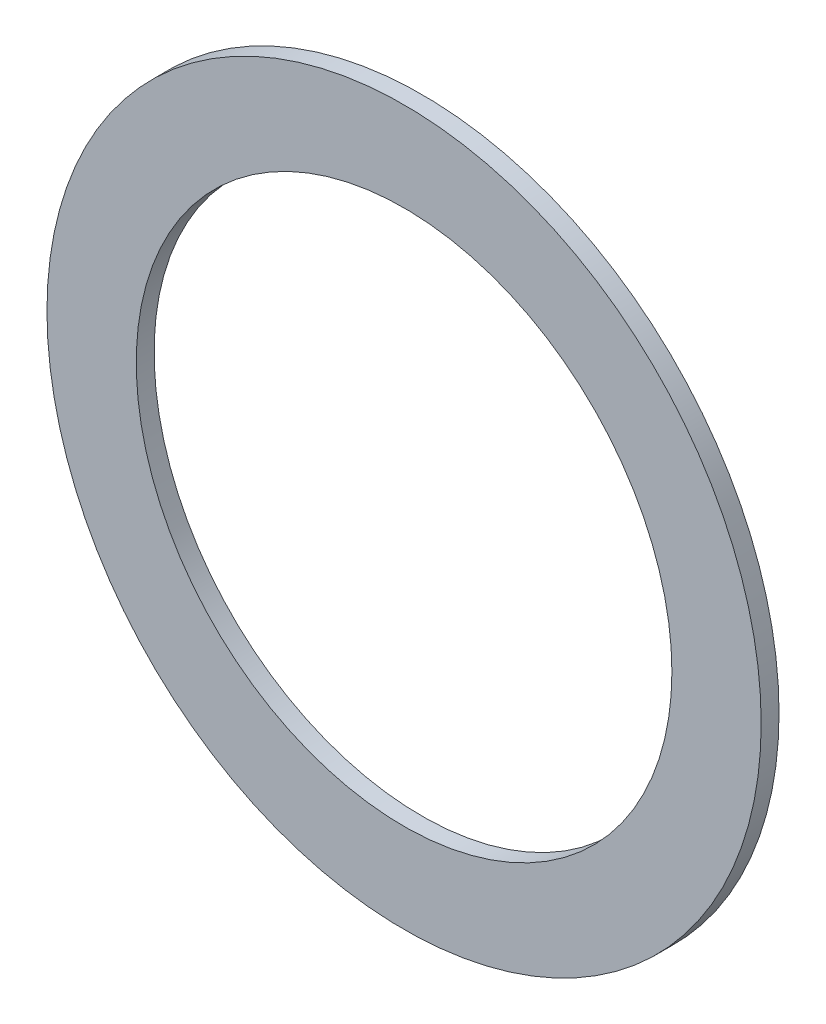
from build123d import *

# Parameters (mm, degrees)
SKETCH1_R           = 100
BOSS_EXTRUDE1_DEPTH = 5
SKETCH2_R           = 75
CUT_EXTRUDE1_DEPTH  = 6


with BuildPart() as part:
    # Sketch1 → Boss-Extrude1 (new body)
    with BuildSketch(Plane.XY):
        Circle(SKETCH1_R)
    extrude(amount=BOSS_EXTRUDE1_DEPTH)

    # Sketch2 → Cut-Extrude1 (cut, through all)
    with BuildSketch(Plane.XY.offset(5)):
        Circle(SKETCH2_R)
    extrude(amount=-CUT_EXTRUDE1_DEPTH, mode=Mode.SUBTRACT)


solid = part.part
